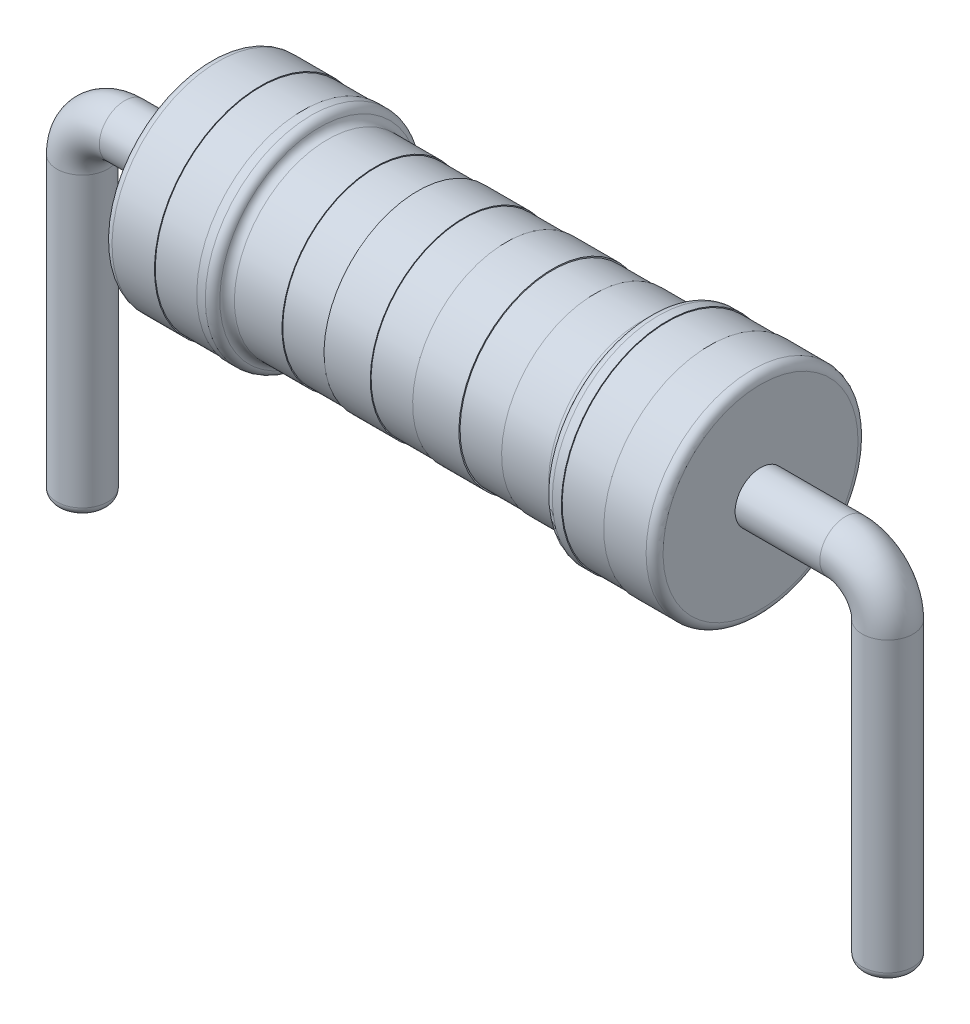
from build123d import *

# Parameters (mm, degrees)
FILLET3_R = 0.1
FILLET4_R = 0.1
FILLET5_R = 0.1
SKETCH2_R = 0.3
FILLET6_R = 0.1


with BuildPart() as part:
    # Sketch1 → Revolve3 (revolve)
    with BuildSketch(Plane.XY):
        Polygon((-3.25, 0), (3.25, 0), (3.25, -1.25), (2.65, -1.25), (2.65, -1.24), (2.15, -1.24), (2.15, -1.25), (1.95, -1.25), (1.95, -1.1), (1.295523437, -1.1), (1.295523437, -1.09), (0.795523437, -1.09), (0.795523437, -1.1037537), (0.25, -1.1037537), (0.25, -1.0937537), (-0.25, -1.0937537), (-0.25, -1.1037537), (-0.795523437, -1.1037537), (-0.795523437, -1.09), (-1.295523437, -1.09), (-1.295523437, -1.1), (-1.95, -1.1), (-1.95, -1.25), (-2.15, -1.25), (-2.15, -1.24), (-2.65, -1.24), (-2.65, -1.25), (-3.25, -1.25), align=None)
    revolve(axis=Axis((-3.25, 0, 0), (1, 0, 0)))

    # Fillet3
    fillet3_edges = [part.edges().sort_by_distance(p)[0] for p in [
        (-3.25, 1.25, 0),
        (1.95, 1.1, 0),
    ]]
    fillet(fillet3_edges, radius=FILLET3_R)

    # Fillet4
    fillet4_edges = [part.edges().sort_by_distance(p)[0] for p in [
        (1.95, 1.25, 0),
        (-1.95, 1.25, 0),
    ]]
    fillet(fillet4_edges, radius=FILLET4_R)

    # Fillet5
    fillet5_edges = [part.edges().sort_by_distance(p)[0] for p in [
        (-1.95, 1.1, 0),
        (3.25, 1.25, 0),
    ]]
    fillet(fillet5_edges, radius=FILLET5_R)

    # Sweep1: sweep along a curve in space
    with BuildLine() as sweep1_path:
        Line((3.25, 0, 0), (4.25, 0, 0))
        ThreePointArc((4.75, -0.5, 0), (4.603553391, -0.146446609, 0), (4.25, 0, 0))
        Line((4.75, -0.5, 0), (4.75, -4, 0))
    # Sketch2 → Sweep1 (sweep)
    with BuildSketch(Plane(origin=(3.25, 0, 0), x_dir=(0, 0, -1), z_dir=(1, 0, 0))):
        Circle(SKETCH2_R)
    sweep1 = sweep(path=sweep1_path.line)

    # Mirror1: Sweep1 across plane
    add(sweep1.mirror(Plane(origin=(0, 0, 0), x_dir=(0, 0, 1), z_dir=(1, 0, 0))))

    # Fillet6
    fillet6_edges = [part.edges().sort_by_distance(p)[0] for p in [
        (4.75, -4, 0.3),
        (-4.75, -4, 0.3),
    ]]
    fillet(fillet6_edges, radius=FILLET6_R)


solid = part.part
